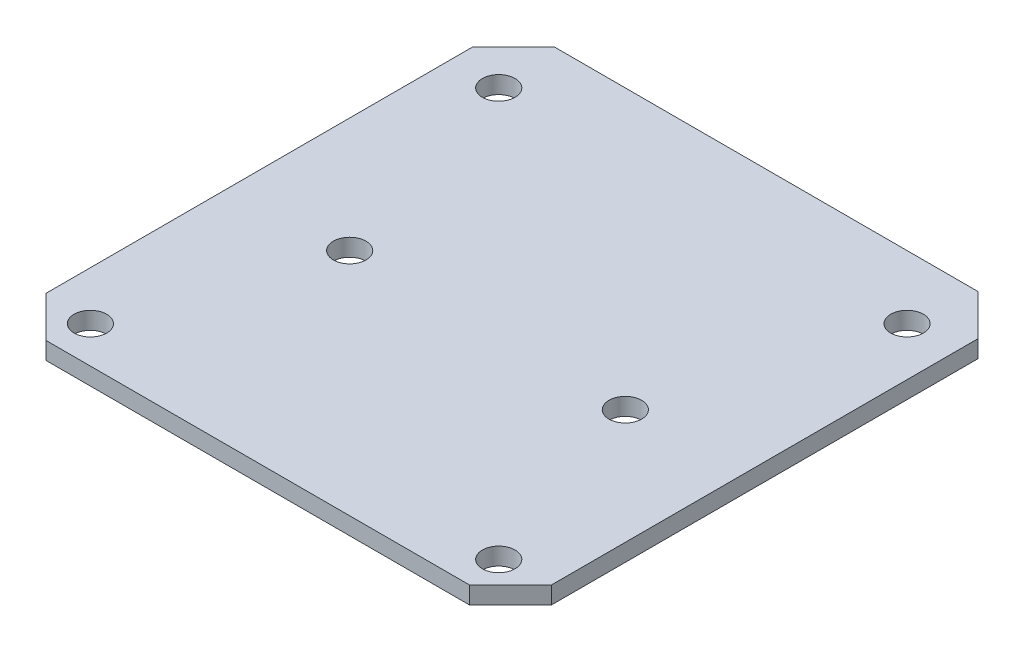
from build123d import *

# Parameters (mm, degrees)
SKETCH1_W            = 49.5
SKETCH1_H            = 49.8
BOSS_EXTRUDE1_DEPTH  = 1.7
M3_CLEARANCE_HOLE1_D = 3.2
LPATTERN1_COUNT      = 2
LPATTERN1_PITCH      = 40
LPATTERN1_COPY_1_D   = 3.2
M3_CLEARANCE_HOLE2_D = 3.2
CHAMFER1_SIZE        = 4


with BuildPart() as part:
    # Sketch1 → Boss-Extrude1 (new body)
    with BuildSketch(Plane(origin=(0, 0, 0), x_dir=(1, 0, 0), z_dir=(0, 1, 0))):
        Rectangle(SKETCH1_W, SKETCH1_H)
    extrude(amount=BOSS_EXTRUDE1_DEPTH)

    # M3 Clearance Hole1 (through all)
    with Locations(Plane(origin=(0, 1.7, 0), x_dir=(1, 0, 0), z_dir=(0, 1, 0))):
        with Locations((-20, 18.7)):
            m3_clearance_hole1 = Hole(M3_CLEARANCE_HOLE1_D / 2)

    # Mirror1: M3 Clearance Hole1 across plane
    add(m3_clearance_hole1.mirror(Plane(origin=(0, 0, 0), x_dir=(0, 0, 1), z_dir=(1, 0, 0))), mode=Mode.SUBTRACT)

    # LPattern1: M3 Clearance Hole1 ×2
    with Locations(*[(0, 0, i * LPATTERN1_PITCH) for i in range(1, LPATTERN1_COUNT)]):
        add(m3_clearance_hole1, mode=Mode.SUBTRACT)

    # LPattern1 copy 1 (through all)
    with Locations(Plane(origin=(0, 1.7, 40), x_dir=(-1, 0, 0), z_dir=(0, 1, 0))):
        with Locations((-20, -18.7)):
            Hole(LPATTERN1_COPY_1_D / 2)

    # M3 Clearance Hole2 (through all)
    with Locations(Plane(origin=(0, 1.7, 0), x_dir=(1, 0, 0), z_dir=(0, 1, 0))):
        with Locations((13.5, -2.4)):
            m3_clearance_hole2 = Hole(M3_CLEARANCE_HOLE2_D / 2)

    # Mirror3: M3 Clearance Hole2 across plane
    add(m3_clearance_hole2.mirror(Plane(origin=(0, 0, 0), x_dir=(0, 0, 1), z_dir=(1, 0, 0))), mode=Mode.SUBTRACT)

    # Chamfer1
    chamfer1_edges = [part.edges().sort_by_distance(p)[0] for p in [
        (24.75, 0.85, 24.9),
        (-24.75, 0.85, 24.9),
        (-24.75, 0.85, -24.9),
        (24.75, 0.85, -24.9),
    ]]
    chamfer(chamfer1_edges, length=CHAMFER1_SIZE)


solid = part.part
